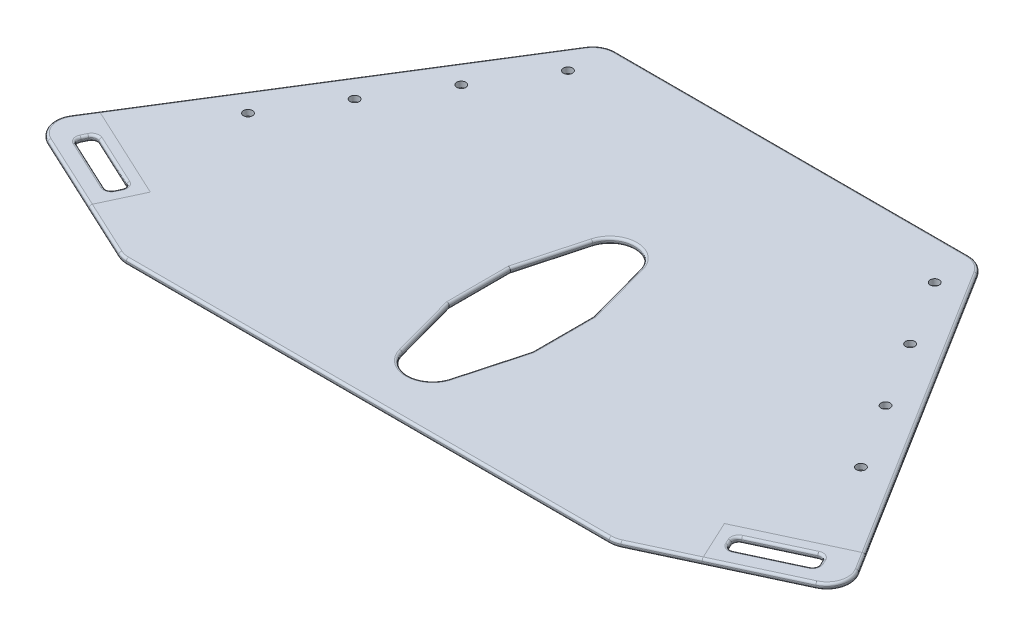
from build123d import *

# Parameters (mm, degrees)
BOSS_EXTRUDE1_DEPTH         = 6.35
CUT_EXTRUDE1_DEPTH          = 7.35
FILLET3_R                   = 6.35
FILLET4_R                   = 2.54
FILLET3_OF_MIRROR1_R        = 6.35
FILLET4_OF_MIRROR1_R        = 2.54
F_3_8_CLEARANCE_HOLE1_D     = 10.0838
F_3_8_CLEARANCE_HOLE1_DEPTH = 6.35
FILLET1_R                   = 25.4
FILLET2_R                   = 2.54
FILLET5_R                   = 2.54


with BuildPart() as part:
    # Sketch1 → Boss-Extrude1 (new body)
    with BuildSketch(Plane(origin=(0, 0, 0), x_dir=(1, 0, 0), z_dir=(0, 1, 0))):
        Polygon((451.38825085, -168.145916122), (273.05, -251.306408235), (-273.05, -251.306408235), (-451.38825085, -168.145916122), (-209.55, 218.593591765), (0, 218.593591765), (209.55, 218.593591765), align=None)
        with BuildLine():
            Line((46.037437645, -47.380178317), (26.459026194, 24.158762711))
            ThreePointArc((26.459026194, 24.158762711), (0, 44.349591757), (-26.459026194, 24.158762711))
            Line((-26.459026194, 24.158762711), (-46.037437638, -47.380178321))
            Line((-46.037437638, -47.380178321), (-46.037437643, -115.126638135))
            Line((-46.037437643, -115.126638135), (-26.459026194, -186.665579187))
            ThreePointArc((-26.459026194, -186.665579187), (-1e-09, -206.856408235), (26.459026194, -186.665579189))
            Line((26.459026194, -186.665579189), (46.037437641, -115.126638134))
            Line((46.037437641, -115.126638134), (46.037437645, -47.380178317))
        make_face(mode=Mode.SUBTRACT)
    extrude(amount=BOSS_EXTRUDE1_DEPTH)

    # Sketch2 → Cut-Extrude1 (cut, through all)
    with BuildSketch(Plane(origin=(0, 6.35, 0), x_dir=(1, 0, 0), z_dir=(0, 1, 0))):
        Polygon((-342.9, -197.715468957), (-411.960653372, -165.511957412), (-403.909775486, -148.246794069), (-334.849122114, -180.450305614), align=None)
    cut_extrude1 = extrude(amount=-CUT_EXTRUDE1_DEPTH, mode=Mode.SUBTRACT)

    # Fillet3
    fillet3_edges = [part.edges().sort_by_distance(p)[0] for p in [
        (-334.849122114, 3.175, 180.450305614),
        (-342.9, 3.175, 197.715468957),
        (-411.960653372, 3.175, 165.511957412),
        (-403.909775486, 3.175, 148.246794069),
    ]]
    fillet(fillet3_edges, radius=FILLET3_R)

    # Fillet4
    fillet4_edges = [part.edges().sort_by_distance(p)[0] for p in [
        (-369.3794488, 6.35, 164.348549841),
        (-369.3794488, 0, 164.348549841),
        (-338.874561057, 6.35, 189.082887285),
        (-338.874561057, 0, 189.082887285),
        (-377.430326686, 6.35, 181.613713184),
        (-377.430326686, 0, 181.613713184),
        (-407.935214429, 6.35, 156.87937574),
        (-407.935214429, 0, 156.87937574),
        (-337.320754382, 6.35, 181.349906189),
        (-337.320754382, 0, 181.349906189),
        (-343.799600576, 6.35, 195.243836689),
        (-343.799600576, 0, 195.243836689),
        (-409.489021104, 6.35, 164.612356836),
        (-409.489021104, 0, 164.612356836),
        (-403.010174911, 6.35, 150.718426337),
        (-403.010174911, 0, 150.718426337),
    ]]
    fillet(fillet4_edges, radius=FILLET4_R)

    # Mirror1: Cut-Extrude1 across plane
    add(cut_extrude1.mirror(Plane(origin=(0, 0, 0), x_dir=(0, 0, 1), z_dir=(1, 0, 0))), mode=Mode.SUBTRACT)

    # Fillet3 of Mirror1
    fillet3_of_mirror1_edges = [part.edges().sort_by_distance(p)[0] for p in [
        (334.849122114, 3.175, 180.450305614),
        (342.9, 3.175, 197.715468957),
        (411.960653372, 3.175, 165.511957412),
        (403.909775486, 3.175, 148.246794069),
    ]]
    fillet(fillet3_of_mirror1_edges, radius=FILLET3_OF_MIRROR1_R)

    # Fillet4 of Mirror1
    fillet4_of_mirror1_edges = [part.edges().sort_by_distance(p)[0] for p in [
        (369.3794488, 6.35, 164.348549841),
        (369.3794488, 0, 164.348549841),
        (338.874561057, 6.35, 189.082887285),
        (338.874561057, 0, 189.082887285),
        (377.430326686, 6.35, 181.613713184),
        (377.430326686, 0, 181.613713184),
        (407.935214429, 6.35, 156.87937574),
        (407.935214429, 0, 156.87937574),
        (337.320754382, 6.35, 181.349906189),
        (337.320754382, 0, 181.349906189),
        (343.799600576, 6.35, 195.243836689),
        (343.799600576, 0, 195.243836689),
        (409.489021104, 6.35, 164.612356836),
        (409.489021104, 0, 164.612356836),
        (403.010174911, 6.35, 150.718426337),
        (403.010174911, 0, 150.718426337),
    ]]
    fillet(fillet4_of_mirror1_edges, radius=FILLET4_OF_MIRROR1_R)

    # 3/8 Clearance Hole1
    with Locations(Plane(origin=(0, 6.35, 0), x_dir=(1, 0, 0), z_dir=(0, 1, 0))):
        with Locations((339.491169359, -44.551324404), (294.039974906, 28.132680355), (248.588780453, 100.816685114), (203.137586, 173.500689873), (-203.137586, 173.500689873), (-248.588780453, 100.816685114), (-294.039974906, 28.132680355), (-339.491169359, -44.551324404)):
            Hole(F_3_8_CLEARANCE_HOLE1_D / 2, depth=F_3_8_CLEARANCE_HOLE1_DEPTH)

    # Fillet1
    fillet1_edges = [part.edges().sort_by_distance(p)[0] for p in [
        (209.55, 3.175, -218.593591765),
        (451.38825085, 3.175, 168.145916122),
        (273.05, 3.175, 251.306408235),
        (-273.05, 3.175, 251.306408235),
        (-451.38825085, 3.175, 168.145916122),
        (-209.55, 3.175, -218.593591765),
    ]]
    fillet(fillet1_edges, radius=FILLET1_R)

    # Fillet2
    fillet2_edges = [part.edges().sort_by_distance(p)[0] for p in [
        (0, 0, -44.349591757),
        (-36.248231916, 0, 11.610707805),
        (-46.03743764, 0, 81.253408228),
        (-36.248231918, 0, 150.896108661),
        (0, 0, 206.856408235),
        (36.248231917, 0, 150.896108662),
        (46.037437643, 0, 81.253408226),
        (36.24823192, 0, 11.610707803),
        (0, 6.35, -44.349591757),
        (-36.248231916, 6.35, 11.610707805),
        (-46.03743764, 6.35, 81.253408228),
        (-36.248231918, 6.35, 150.896108661),
        (0, 6.35, 206.856408235),
        (36.248231917, 6.35, 150.896108662),
        (46.037437643, 6.35, 81.253408226),
        (36.24823192, 6.35, 11.610707803),
    ]]
    fillet(fillet2_edges, radius=FILLET2_R)

    # Fillet5
    fillet5_edges = [part.edges().sort_by_distance(p)[0] for p in [
        (-326.586759431, 0, -31.432385512),
        (-326.586759431, 6.35, -31.432385512),
        (0, 0, -218.593591765),
        (326.586759431, 0, -31.432385512),
        (351.756739502, 0, 214.604852857),
        (0, 0, 251.306408235),
        (-351.756739502, 0, 214.604852857),
        (272.916521763, 0, 250.704326816),
        (438.980720898, 0, 164.472853689),
        (-272.916521763, 0, 250.704326816),
        (-438.980720898, 0, 164.472853689),
        (207.786517704, 0, -215.410953475),
        (-207.786517704, 0, -215.410953475),
        (0, 6.35, -218.593591765),
        (0, 6.35, 251.306408235),
        (351.756739502, 6.35, 214.604852857),
        (272.916521763, 6.35, 250.704326816),
        (-272.916521763, 6.35, 250.704326816),
        (207.786517704, 6.35, -215.410953475),
        (-207.786517704, 6.35, -215.410953475),
        (326.586759431, 6.35, -31.432385512),
        (-351.756739502, 6.35, 214.604852857),
        (-438.980720898, 6.35, 164.472853689),
        (438.980720898, 6.35, 164.472853689),
        (-326.586759431, 6.35, -31.432385512),
        (-351.756739502, 6.35, 214.604852857),
        (351.756739502, 6.35, 214.604852857),
        (326.586759431, 6.35, -31.432385512),
    ]]
    fillet(fillet5_edges, radius=FILLET5_R)


solid = part.part
